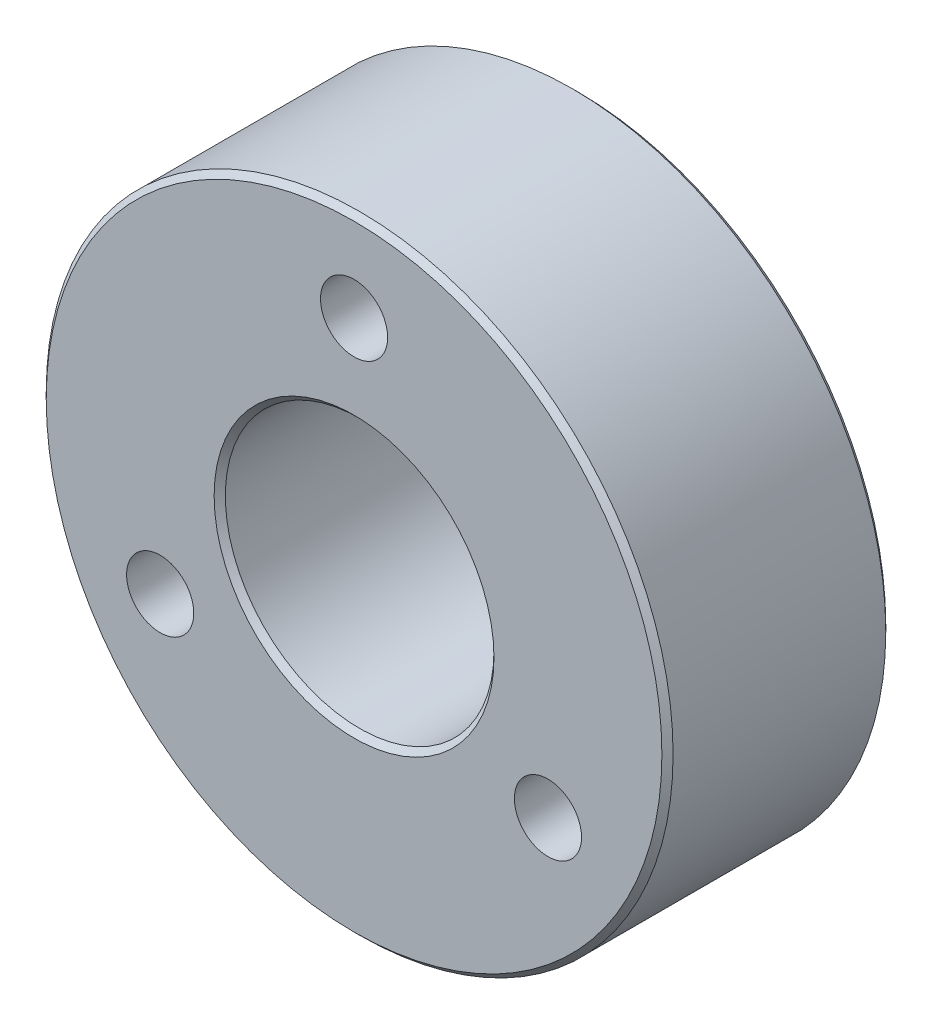
from build123d import *

# Parameters (mm, degrees)
SKETCH1_R           = 14
SKETCH1_R_2         = 6
SKETCH1_R_3         = 1.5
BOSS_EXTRUDE1_DEPTH = 5
CHAMFER1_SIZE       = 0.25


with BuildPart() as part:
    # Sketch1 → Boss-Extrude1 (new body, symmetric)
    with BuildSketch(Plane.XY):
        Circle(SKETCH1_R)
        Circle(SKETCH1_R_2, mode=Mode.SUBTRACT)
        with Locations((0, 10)):
            Circle(SKETCH1_R_3, mode=Mode.SUBTRACT)
        with Locations((8.660254038, -5)):
            Circle(SKETCH1_R_3, mode=Mode.SUBTRACT)
        with Locations((-8.660254038, -5)):
            Circle(SKETCH1_R_3, mode=Mode.SUBTRACT)
    extrude(amount=BOSS_EXTRUDE1_DEPTH, both=True)

    # Chamfer1
    chamfer1_edges = [part.edges().sort_by_distance(p)[0] for p in [
        (-14, 0, -5),
        (-14, 0, 5),
        (-6, 0, -5),
        (-6, 0, 5),
    ]]
    chamfer(chamfer1_edges, length=CHAMFER1_SIZE)


solid = part.part
